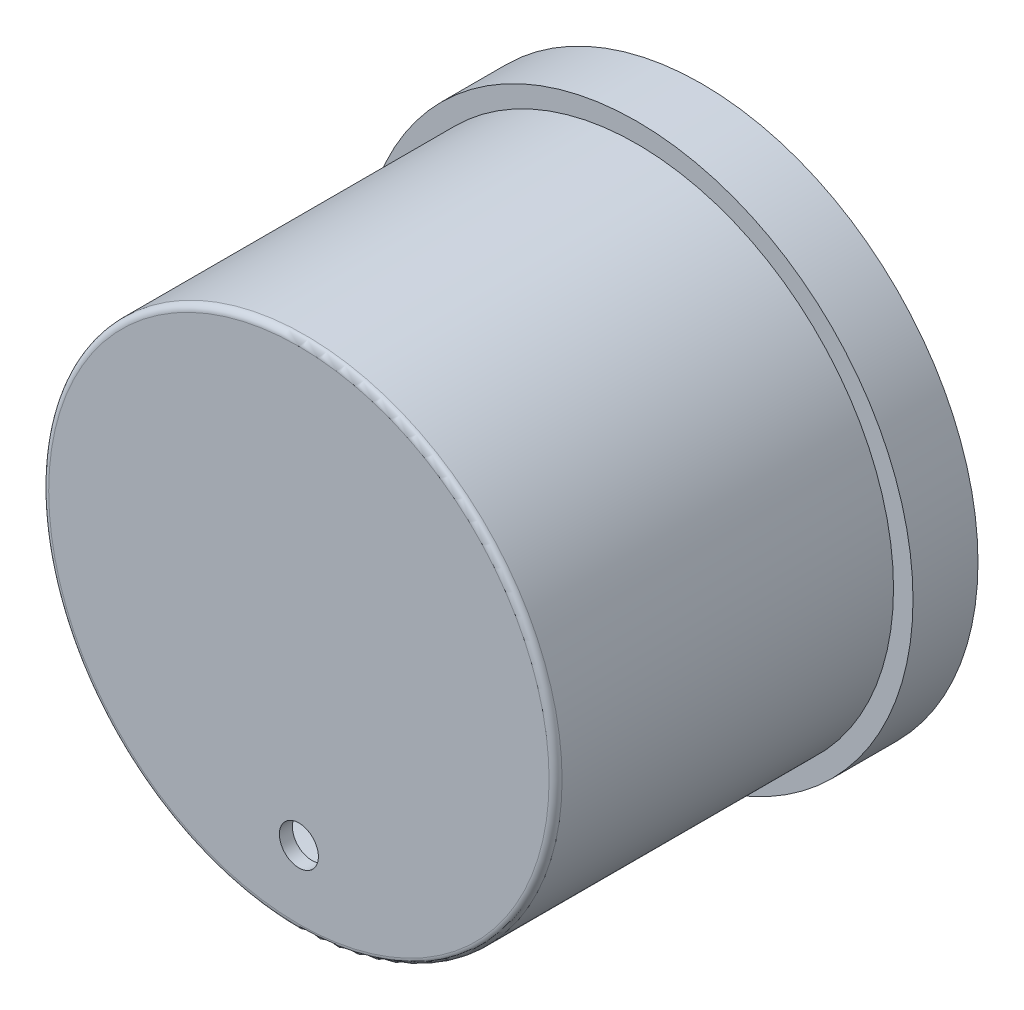
from build123d import *

# Parameters (mm, degrees)
SKETCH1_R           = 42.5
SKETCH1_R_2         = 37.5
BOSS_EXTRUDE1_DEPTH = 10
SKETCH2_R           = 39.5
SKETCH2_R_2         = 37.5
BOSS_EXTRUDE2_DEPTH = 50
SKETCH3_R           = 39.5
BOSS_EXTRUDE3_DEPTH = 2
FILLET1_R           = 1
CUT_EXTRUDE1_DEPTH  = 100


with BuildPart() as part:
    # Sketch1 → Boss-Extrude1 (new body)
    with BuildSketch(Plane.XY):
        Circle(SKETCH1_R)
        Circle(SKETCH1_R_2, mode=Mode.SUBTRACT)
    extrude(amount=BOSS_EXTRUDE1_DEPTH)

    # Sketch2 → Boss-Extrude2 (add)
    with BuildSketch(Plane.XY.offset(10)):
        Circle(SKETCH2_R)
        Circle(SKETCH2_R_2, mode=Mode.SUBTRACT)
    extrude(amount=BOSS_EXTRUDE2_DEPTH)

    # Sketch3 → Boss-Extrude3 (add)
    with BuildSketch(Plane.XY.offset(60)):
        Circle(SKETCH3_R)
    extrude(amount=BOSS_EXTRUDE3_DEPTH)

    # Fillet1
    fillet1_edges = [part.edges().sort_by_distance(p)[0] for p in [
        (-39.5, 0, 62),
    ]]
    fillet(fillet1_edges, radius=FILLET1_R)

    # Sketch4 → Cut-Extrude1 (cut)
    with BuildSketch(Plane.XY.offset(62)):
        with BuildLine():
            ThreePointArc((0, -25.004064668), (-3, -28.004064668), (0, -31.004064668))
            Line((0, -31.004064668), (0, -25.004064668))
        make_face()
        with BuildLine():
            Line((0, -25.004064668), (0, -31.004064668))
            ThreePointArc((0, -31.004064668), (2.121320344, -30.125385012), (3, -28.004064668))
            ThreePointArc((3, -28.004064668), (2.121320344, -25.882744324), (0, -25.004064668))
        make_face()
    extrude(amount=-CUT_EXTRUDE1_DEPTH, mode=Mode.SUBTRACT)


solid = part.part
